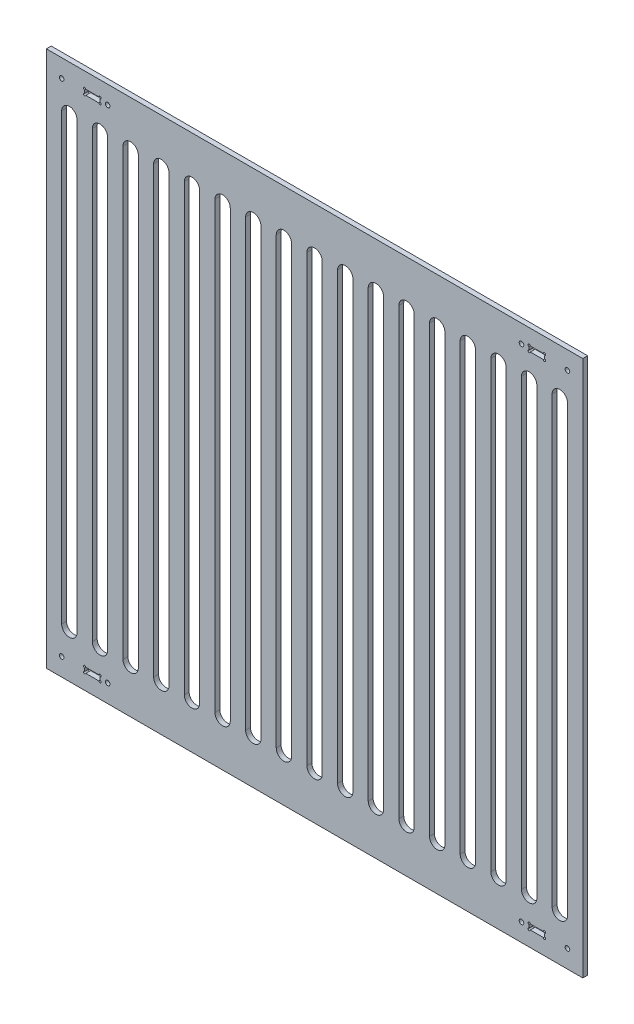
from build123d import *

# Parameters (mm, degrees)
SKETCH1_W                 = 700
SKETCH1_H                 = 700
BOSS_EXTRUDE1_DEPTH       = 6.35
SKETCH2_R                 = 1.5
SKETCH2_W                 = 20
SKETCH2_H                 = 6.858
SKETCH2_R_2               = 3
CUT_EXTRUDE1_DEPTH        = 7.35
MIRROR2_COPY_1_SKETCH_R   = 1.5
MIRROR2_COPY_1_SKETCH_W   = 20
MIRROR2_COPY_1_SKETCH_H   = 6.858
MIRROR2_COPY_1_SKETCH_R_2 = 3
MIRROR2_COPY_1_DEPTH      = 7.35
CUT_EXTRUDE2_DEPTH        = 7.35
LPATTERN1_COUNT           = 9
LPATTERN1_PITCH           = 40
MIRROR3_COPY_1_DEPTH      = 7.35
MIRROR3_COPY_2_DEPTH      = 7.35
MIRROR3_COPY_3_DEPTH      = 7.35
MIRROR3_COPY_4_DEPTH      = 7.35
MIRROR3_COPY_5_DEPTH      = 7.35
MIRROR3_COPY_6_DEPTH      = 7.35
MIRROR3_COPY_7_DEPTH      = 7.35
MIRROR3_COPY_8_DEPTH      = 7.35
MIRROR3_COPY_9_DEPTH      = 7.35


with BuildPart() as part:
    # Sketch1 → Boss-Extrude1 (new body)
    with BuildSketch(Plane.XY):
        Rectangle(SKETCH1_W, SKETCH1_H)
    extrude(amount=BOSS_EXTRUDE1_DEPTH)

    # Sketch2 → Cut-Extrude1 (cut, through all)
    with BuildSketch(Plane.XY.offset(6.35)):
        with Locations((-280, 323.142)):
            Circle(SKETCH2_R)
        with Locations((-280, 330)):
            Circle(SKETCH2_R)
        with Locations((-300, 330)):
            Circle(SKETCH2_R)
        with Locations((-300, 323.142)):
            Circle(SKETCH2_R)
        with Locations((-290, 326.571)):
            Rectangle(SKETCH2_W, SKETCH2_H)
        with BuildLine():
            Line((-300, 328.5), (-300, 330))
            Line((-300, 330), (-298.5, 330))
            ThreePointArc((-298.5, 330), (-301.060660172, 331.060660172), (-300, 328.5))
        make_face()
        with BuildLine():
            Line((-298.5, 330), (-300, 330))
            Line((-300, 330), (-300, 328.5))
            ThreePointArc((-300, 328.5), (-298.939339828, 328.939339828), (-298.5, 330))
        make_face()
        with BuildLine():
            ThreePointArc((-298.5, 323.142), (-298.939339828, 324.202660172), (-300, 324.642))
            Line((-300, 324.642), (-300, 323.142))
            Line((-300, 323.142), (-298.5, 323.142))
        make_face()
        with BuildLine():
            Line((-300, 323.142), (-300, 324.642))
            ThreePointArc((-300, 324.642), (-301.060660172, 322.081339828), (-298.5, 323.142))
            Line((-298.5, 323.142), (-300, 323.142))
        make_face()
        with BuildLine():
            ThreePointArc((-278.5, 330), (-280, 331.5), (-281.5, 330))
            Line((-281.5, 330), (-280, 330))
            Line((-280, 330), (-280, 328.5))
            ThreePointArc((-280, 328.5), (-278.939339828, 328.939339828), (-278.5, 330))
        make_face()
        with BuildLine():
            Line((-280, 330), (-281.5, 330))
            ThreePointArc((-281.5, 330), (-281.060660172, 328.939339828), (-280, 328.5))
            Line((-280, 328.5), (-280, 330))
        make_face()
        with BuildLine():
            ThreePointArc((-278.5, 323.142), (-278.939339828, 324.202660172), (-280, 324.642))
            Line((-280, 324.642), (-280, 323.142))
            Line((-280, 323.142), (-281.5, 323.142))
            ThreePointArc((-281.5, 323.142), (-280, 321.642), (-278.5, 323.142))
        make_face()
        with BuildLine():
            Line((-280, 323.142), (-280, 324.642))
            ThreePointArc((-280, 324.642), (-281.060660172, 324.202660172), (-281.5, 323.142))
            Line((-281.5, 323.142), (-280, 323.142))
        make_face()
        with Locations((-330, 326.57)):
            Circle(SKETCH2_R_2)
        with Locations((-270, 326.57)):
            Circle(SKETCH2_R_2)
    cut_extrude1 = extrude(amount=-CUT_EXTRUDE1_DEPTH, mode=Mode.SUBTRACT)

    # Mirror1: Cut-Extrude1 across plane
    add(cut_extrude1.mirror(Plane.ZX), mode=Mode.SUBTRACT)

    # Mirror2: Cut-Extrude1 across plane
    add(cut_extrude1.mirror(Plane(origin=(0, 0, 0), x_dir=(0, 0, 1), z_dir=(1, 0, 0))), mode=Mode.SUBTRACT)

    # Mirror2 copy 1 sketch → Mirror2 copy 1 (cut, through all)
    with BuildSketch(Plane(origin=(0, 0, 6.35), x_dir=(-1, 0, 0), z_dir=(0, 0, 1))):
        with Locations((-280, 323.142)):
            Circle(MIRROR2_COPY_1_SKETCH_R)
        with Locations((-280, 330)):
            Circle(MIRROR2_COPY_1_SKETCH_R)
        with Locations((-300, 330)):
            Circle(MIRROR2_COPY_1_SKETCH_R)
        with Locations((-300, 323.142)):
            Circle(MIRROR2_COPY_1_SKETCH_R)
        with Locations((-290, 326.571)):
            Rectangle(MIRROR2_COPY_1_SKETCH_W, MIRROR2_COPY_1_SKETCH_H)
        with BuildLine():
            Line((-300, 328.5), (-300, 330))
            Line((-300, 330), (-298.5, 330))
            ThreePointArc((-298.5, 330), (-301.060660172, 331.060660172), (-300, 328.5))
        make_face()
        with BuildLine():
            Line((-298.5, 330), (-300, 330))
            Line((-300, 330), (-300, 328.5))
            ThreePointArc((-300, 328.5), (-298.939339828, 328.939339828), (-298.5, 330))
        make_face()
        with BuildLine():
            ThreePointArc((-298.5, 323.142), (-298.939339828, 324.202660172), (-300, 324.642))
            Line((-300, 324.642), (-300, 323.142))
            Line((-300, 323.142), (-298.5, 323.142))
        make_face()
        with BuildLine():
            Line((-300, 323.142), (-300, 324.642))
            ThreePointArc((-300, 324.642), (-301.060660172, 322.081339828), (-298.5, 323.142))
            Line((-298.5, 323.142), (-300, 323.142))
        make_face()
        with BuildLine():
            ThreePointArc((-278.5, 330), (-280, 331.5), (-281.5, 330))
            Line((-281.5, 330), (-280, 330))
            Line((-280, 330), (-280, 328.5))
            ThreePointArc((-280, 328.5), (-278.939339828, 328.939339828), (-278.5, 330))
        make_face()
        with BuildLine():
            Line((-280, 330), (-281.5, 330))
            ThreePointArc((-281.5, 330), (-281.060660172, 328.939339828), (-280, 328.5))
            Line((-280, 328.5), (-280, 330))
        make_face()
        with BuildLine():
            ThreePointArc((-278.5, 323.142), (-278.939339828, 324.202660172), (-280, 324.642))
            Line((-280, 324.642), (-280, 323.142))
            Line((-280, 323.142), (-281.5, 323.142))
            ThreePointArc((-281.5, 323.142), (-280, 321.642), (-278.5, 323.142))
        make_face()
        with BuildLine():
            Line((-280, 323.142), (-280, 324.642))
            ThreePointArc((-280, 324.642), (-281.060660172, 324.202660172), (-281.5, 323.142))
            Line((-281.5, 323.142), (-280, 323.142))
        make_face()
        with Locations((-330, 326.57)):
            Circle(MIRROR2_COPY_1_SKETCH_R_2)
        with Locations((-270, 326.57)):
            Circle(MIRROR2_COPY_1_SKETCH_R_2)
    extrude(amount=-MIRROR2_COPY_1_DEPTH, mode=Mode.SUBTRACT)

    # Sketch3 → Cut-Extrude2 (cut, through all)
    with BuildSketch(Plane.XY.offset(6.35)):
        with BuildLine():
            Line((10, 290), (10, -290))
            ThreePointArc((10, -290), (0, -300), (-10, -290))
            Line((-10, -290), (-10, 290))
            ThreePointArc((-10, 290), (0, 300), (10, 290))
        make_face()
    cut_extrude2 = extrude(amount=-CUT_EXTRUDE2_DEPTH, mode=Mode.SUBTRACT)

    # LPattern1: Cut-Extrude2 ×9
    with Locations(*[(i * LPATTERN1_PITCH, 0, 0) for i in range(1, LPATTERN1_COUNT)]):
        add(cut_extrude2, mode=Mode.SUBTRACT)

    # Mirror3 copy 1 sketch → Mirror3 copy 1 (cut, through all)
    with BuildSketch(Plane(origin=(-40, 0, 6.35), x_dir=(-1, 0, 0), z_dir=(0, 0, 1))):
        with BuildLine():
            Line((10, -290), (10, 290))
            ThreePointArc((10, 290), (0, 300), (-10, 290))
            Line((-10, 290), (-10, -290))
            ThreePointArc((-10, -290), (0, -300), (10, -290))
        make_face()
    extrude(amount=-MIRROR3_COPY_1_DEPTH, mode=Mode.SUBTRACT)

    # Mirror3 copy 2 sketch → Mirror3 copy 2 (cut, through all)
    with BuildSketch(Plane(origin=(-80, 0, 6.35), x_dir=(-1, 0, 0), z_dir=(0, 0, 1))):
        with BuildLine():
            Line((10, -290), (10, 290))
            ThreePointArc((10, 290), (0, 300), (-10, 290))
            Line((-10, 290), (-10, -290))
            ThreePointArc((-10, -290), (0, -300), (10, -290))
        make_face()
    extrude(amount=-MIRROR3_COPY_2_DEPTH, mode=Mode.SUBTRACT)

    # Mirror3 copy 3 sketch → Mirror3 copy 3 (cut, through all)
    with BuildSketch(Plane(origin=(-120, 0, 6.35), x_dir=(-1, 0, 0), z_dir=(0, 0, 1))):
        with BuildLine():
            Line((10, -290), (10, 290))
            ThreePointArc((10, 290), (0, 300), (-10, 290))
            Line((-10, 290), (-10, -290))
            ThreePointArc((-10, -290), (0, -300), (10, -290))
        make_face()
    extrude(amount=-MIRROR3_COPY_3_DEPTH, mode=Mode.SUBTRACT)

    # Mirror3 copy 4 sketch → Mirror3 copy 4 (cut, through all)
    with BuildSketch(Plane(origin=(-160, 0, 6.35), x_dir=(-1, 0, 0), z_dir=(0, 0, 1))):
        with BuildLine():
            Line((10, -290), (10, 290))
            ThreePointArc((10, 290), (0, 300), (-10, 290))
            Line((-10, 290), (-10, -290))
            ThreePointArc((-10, -290), (0, -300), (10, -290))
        make_face()
    extrude(amount=-MIRROR3_COPY_4_DEPTH, mode=Mode.SUBTRACT)

    # Mirror3 copy 5 sketch → Mirror3 copy 5 (cut, through all)
    with BuildSketch(Plane(origin=(-200, 0, 6.35), x_dir=(-1, 0, 0), z_dir=(0, 0, 1))):
        with BuildLine():
            Line((10, -290), (10, 290))
            ThreePointArc((10, 290), (0, 300), (-10, 290))
            Line((-10, 290), (-10, -290))
            ThreePointArc((-10, -290), (0, -300), (10, -290))
        make_face()
    extrude(amount=-MIRROR3_COPY_5_DEPTH, mode=Mode.SUBTRACT)

    # Mirror3 copy 6 sketch → Mirror3 copy 6 (cut, through all)
    with BuildSketch(Plane(origin=(-240, 0, 6.35), x_dir=(-1, 0, 0), z_dir=(0, 0, 1))):
        with BuildLine():
            Line((10, -290), (10, 290))
            ThreePointArc((10, 290), (0, 300), (-10, 290))
            Line((-10, 290), (-10, -290))
            ThreePointArc((-10, -290), (0, -300), (10, -290))
        make_face()
    extrude(amount=-MIRROR3_COPY_6_DEPTH, mode=Mode.SUBTRACT)

    # Mirror3 copy 7 sketch → Mirror3 copy 7 (cut, through all)
    with BuildSketch(Plane(origin=(-280, 0, 6.35), x_dir=(-1, 0, 0), z_dir=(0, 0, 1))):
        with BuildLine():
            Line((10, -290), (10, 290))
            ThreePointArc((10, 290), (0, 300), (-10, 290))
            Line((-10, 290), (-10, -290))
            ThreePointArc((-10, -290), (0, -300), (10, -290))
        make_face()
    extrude(amount=-MIRROR3_COPY_7_DEPTH, mode=Mode.SUBTRACT)

    # Mirror3 copy 8 sketch → Mirror3 copy 8 (cut, through all)
    with BuildSketch(Plane(origin=(-320, 0, 6.35), x_dir=(-1, 0, 0), z_dir=(0, 0, 1))):
        with BuildLine():
            Line((10, -290), (10, 290))
            ThreePointArc((10, 290), (0, 300), (-10, 290))
            Line((-10, 290), (-10, -290))
            ThreePointArc((-10, -290), (0, -300), (10, -290))
        make_face()
    extrude(amount=-MIRROR3_COPY_8_DEPTH, mode=Mode.SUBTRACT)

    # Mirror3 copy 9 sketch → Mirror3 copy 9 (cut, through all)
    with BuildSketch(Plane(origin=(0, 0, 6.35), x_dir=(-1, 0, 0), z_dir=(0, 0, 1))):
        with BuildLine():
            Line((10, -290), (10, 290))
            ThreePointArc((10, 290), (0, 300), (-10, 290))
            Line((-10, 290), (-10, -290))
            ThreePointArc((-10, -290), (0, -300), (10, -290))
        make_face()
    extrude(amount=-MIRROR3_COPY_9_DEPTH, mode=Mode.SUBTRACT)


solid = part.part
